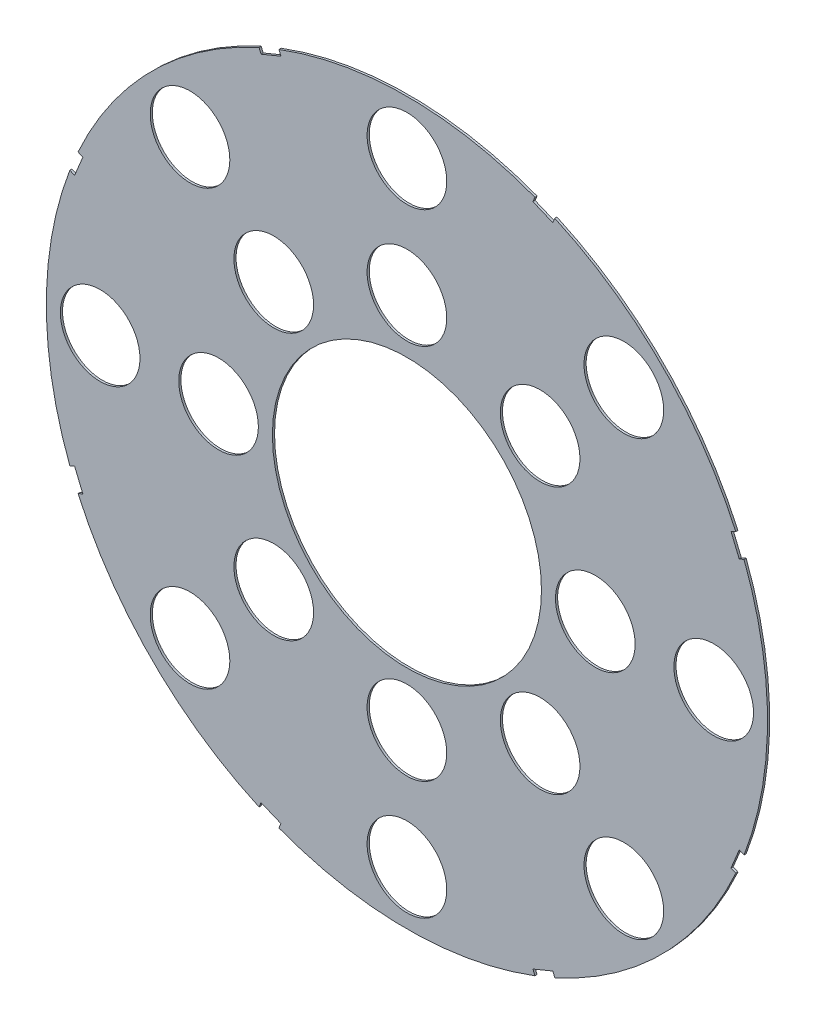
from build123d import *

# Parameters (mm, degrees)
SKETCH4_R           = 42.545
BOSS_EXTRUDE2_DEPTH = 0.254
SKETCH5_R           = 15.875
CUT_EXTRUDE5_DEPTH  = 1.254
CUT_EXTRUDE11_DEPTH = 1.254
SKETCH9_R           = 4.699
CUT_EXTRUDE12_DEPTH = 1.254


with BuildPart() as part:
    # Sketch4 → Boss-Extrude2 (new body)
    with BuildSketch(Plane.XY):
        Circle(SKETCH4_R)
    extrude(amount=BOSS_EXTRUDE2_DEPTH)

    # Sketch5 → Cut-Extrude5 (cut, through all)
    with BuildSketch(Plane.XY.offset(0.254)):
        Circle(SKETCH5_R)
    extrude(amount=-CUT_EXTRUDE5_DEPTH, mode=Mode.SUBTRACT)

    # Sketch8 → Cut-Extrude11 (cut, through all)
    with BuildSketch(Plane.XY.offset(0.254)):
        Polygon((40.379126173, 15.350943603), (39.407110255, 17.697597616), (38.233783248, 17.211589657), (39.205799167, 14.864935644), align=None)
        Polygon((-15.350943603, 40.379126173), (-17.697597616, 39.407110255), (-17.211589657, 38.233783248), (-14.864935644, 39.205799167), align=None)
        Polygon((-39.407110255, 17.697597616), (-40.379126173, 15.350943603), (-39.205799167, 14.864935644), (-38.233783248, 17.211589657), align=None)
        Polygon((-40.379126173, -15.350943603), (-39.407110255, -17.697597616), (-38.233783248, -17.211589657), (-39.205799167, -14.864935644), align=None)
        Polygon((-17.697597616, -39.407110255), (-15.350943603, -40.379126173), (-14.864935644, -39.205799167), (-17.211589657, -38.233783248), align=None)
        Polygon((15.350943603, -40.379126173), (17.697597616, -39.407110255), (17.211589657, -38.233783248), (14.864935644, -39.205799167), align=None)
        Polygon((39.407110255, -17.697597616), (40.379126173, -15.350943603), (39.205799167, -14.864935644), (38.233783248, -17.211589657), align=None)
        Polygon((17.697597616, 39.407110255), (15.350943603, 40.379126173), (14.864935644, 39.205799167), (17.211589657, 38.233783248), align=None)
    extrude(amount=-CUT_EXTRUDE11_DEPTH, mode=Mode.SUBTRACT)

    # Sketch9 → Cut-Extrude12 (cut, through all)
    with BuildSketch(Plane.XY.offset(0.254)):
        with Locations((22.225, 0)):
            Circle(SKETCH9_R)
        with Locations((36.195, 0)):
            Circle(SKETCH9_R)
        with Locations((15.715448212, -15.715448212)):
            Circle(SKETCH9_R)
        with Locations((25.593729945, -25.593729945)):
            Circle(SKETCH9_R)
        with Locations((0, -22.225)):
            Circle(SKETCH9_R)
        with Locations((0, -36.195)):
            Circle(SKETCH9_R)
        with Locations((-15.715448212, -15.715448212)):
            Circle(SKETCH9_R)
        with Locations((-25.593729945, -25.593729945)):
            Circle(SKETCH9_R)
        with Locations((-22.225, 0)):
            Circle(SKETCH9_R)
        with Locations((-36.195, 0)):
            Circle(SKETCH9_R)
        with Locations((-15.715448212, 15.715448212)):
            Circle(SKETCH9_R)
        with Locations((-25.593729945, 25.593729945)):
            Circle(SKETCH9_R)
        with Locations((0, 22.225)):
            Circle(SKETCH9_R)
        with Locations((0, 36.195)):
            Circle(SKETCH9_R)
        with Locations((15.715448212, 15.715448212)):
            Circle(SKETCH9_R)
        with Locations((25.593729945, 25.593729945)):
            Circle(SKETCH9_R)
    extrude(amount=-CUT_EXTRUDE12_DEPTH, mode=Mode.SUBTRACT)


solid = part.part
